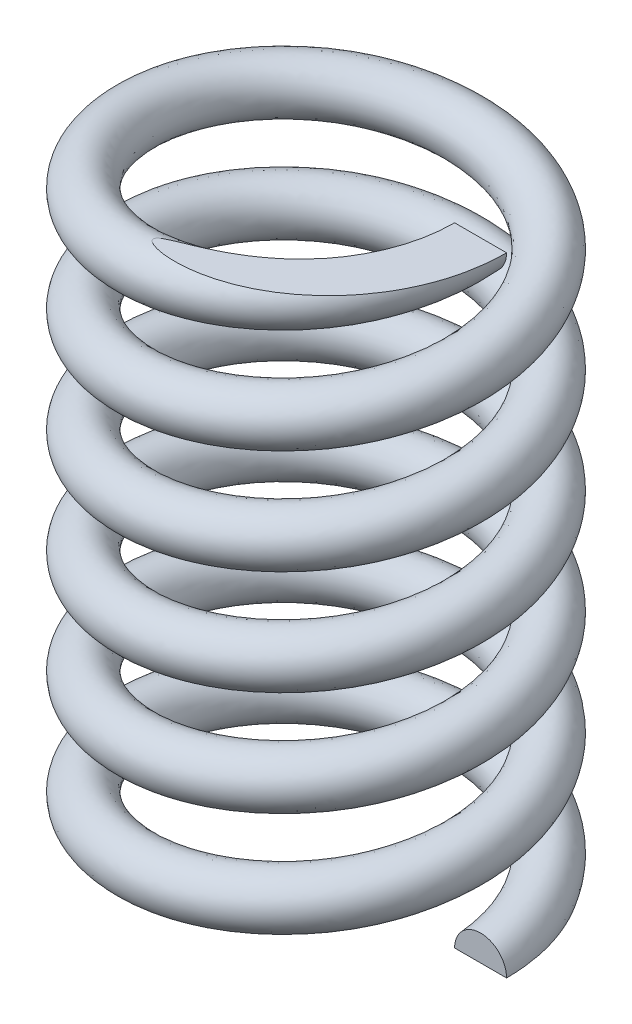
from build123d import *

# Parameters (mm, degrees)
SWEEP_1_PITCH            = 1.208333333
SWEEP_1_HEIGHT           = 7.25
SWEEP_1_RADIUS           = 1.9
SWEEP_1_START_ANGLE      = 90
SKETCH_2_R               = 0.3
SKETCH_3_OUTSIDE_W       = 8.404
SKETCH_3_OUTSIDE_H       = 11.854
SKETCH_3_OUTSIDE_W_2     = 34.401094542
SKETCH_3_OUTSIDE_H_2     = 7.25
CUT_EXTRUDE_1_DEPTH      = 3.200006707
CUT_EXTRUDE_1_DEPTH_BACK = 3.200006707


with BuildPart() as part:
    # По траектории1: sweep along a helix
    with BuildLine() as sweep_1_path:
        add(Helix(SWEEP_1_PITCH, SWEEP_1_HEIGHT, SWEEP_1_RADIUS, center=(0, 0, 0), direction=(0, 1, 0), mode=Mode.PRIVATE).rotate(Axis((0, 0, 0), (0, 1, 0)), SWEEP_1_START_ANGLE))
    # Эскиз2 → По траектории1 (sweep)
    with BuildSketch(Plane.XY):
        with Locations((1.9, 0)):
            Circle(SKETCH_2_R)
    sweep(path=sweep_1_path.line, is_frenet=True)

    # Эскиз3 outside → Вырез-Вытянуть1 (cut, two sides)
    with BuildSketch(Plane.XY) as cut_extrude_1_sk:
        with Locations((0, 3.625)):
            Rectangle(SKETCH_3_OUTSIDE_W, SKETCH_3_OUTSIDE_H)
        with Locations((0, 3.625)):
            Rectangle(SKETCH_3_OUTSIDE_W_2, SKETCH_3_OUTSIDE_H_2, mode=Mode.SUBTRACT)
    extrude(amount=CUT_EXTRUDE_1_DEPTH, mode=Mode.SUBTRACT)
    extrude(cut_extrude_1_sk.sketch, amount=-CUT_EXTRUDE_1_DEPTH_BACK, mode=Mode.SUBTRACT)


solid = part.part
